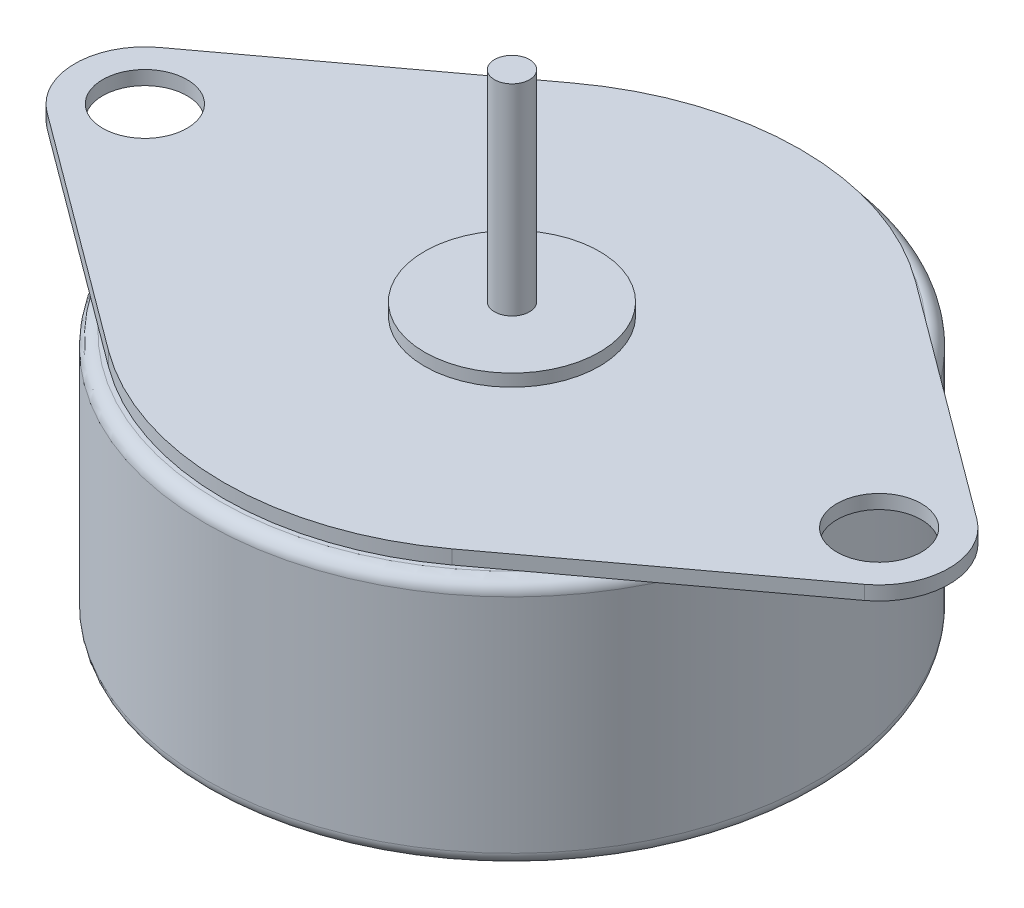
from build123d import *

# Parameters (mm, degrees)
SKETCH1_R      = 17.5
EXTRUDE1_DEPTH = 14.2
FILLET1_R      = 0.75
SKETCH2_R      = 2.413
EXTRUDE2_DEPTH = 0.8
SKETCH3_R      = 5
EXTRUDE3_DEPTH = 2
SKETCH4_R      = 5
EXTRUDE4_DEPTH = 0.7
SKETCH5_R      = 1
EXTRUDE5_DEPTH = 11.5


with BuildPart() as part:
    # Sketch1 → Extrude1 (new body)
    with BuildSketch(Plane(origin=(0, 0, 0), x_dir=(1, 0, 0), z_dir=(0, 1, 0))):
        with Locations(Location((0, 0, 0), (0, 0, 270))):  # turned: the seam where the file's is
            Circle(SKETCH1_R)
    extrude(amount=EXTRUDE1_DEPTH)

    # Fillet1
    fillet1_edges = [part.edges().sort_by_distance(p)[0] for p in [
        (0, 0, -17.5),
        (0, 14.2, -17.5),
    ]]
    fillet(fillet1_edges, radius=FILLET1_R)

    # Sketch2 → Extrude2 (add)
    with BuildSketch(Plane(origin=(0, 14.2, 0), x_dir=(-1, 0, 0), z_dir=(0, 1, 0))):
        with BuildLine():
            Line((23.380952381, -3.21419753), (9.821428571, -13.25856481))
            ThreePointArc((9.821428571, -13.25856481), (0, -16.5), (-9.821428571, -13.25856481))
            Line((-9.821428571, -13.25856481), (-23.380952381, -3.21419753))
            ThreePointArc((-23.380952381, -3.21419753), (-25, 0), (-23.380952381, 3.21419753))
            Line((-23.380952381, 3.21419753), (-9.821428571, 13.25856481))
            ThreePointArc((-9.821428571, 13.25856481), (0, 16.5), (9.821428571, 13.25856481))
            Line((9.821428571, 13.25856481), (23.380952381, 3.21419753))
            ThreePointArc((23.380952381, 3.21419753), (25, 0), (23.380952381, -3.21419753))
        make_face()
        with Locations(Location((21, 0, 0), (0, 0, 90))):  # turned: the seam where the file's is
            Circle(SKETCH2_R, mode=Mode.SUBTRACT)
        with Locations(Location((-21, 0, 0), (0, 0, 270))):  # turned: the seam where the file's is
            Circle(SKETCH2_R, mode=Mode.SUBTRACT)
    extrude(amount=EXTRUDE2_DEPTH)

    # Sketch3 → Extrude3 (add)
    with BuildSketch(Plane.XZ):
        with Locations(Location((0, 0, 0), (0, 0, 90))):  # turned: the seam where the file's is
            Circle(SKETCH3_R)
    extrude(amount=EXTRUDE3_DEPTH)

    # Sketch4 → Extrude4 (add)
    with BuildSketch(Plane(origin=(0, 15, 0), x_dir=(-1, 0, 0), z_dir=(0, 1, 0))):
        with Locations(Location((0, 0, 0), (0, 0, 90))):  # turned: the seam where the file's is
            Circle(SKETCH4_R)
    extrude(amount=EXTRUDE4_DEPTH)

    # Sketch5 → Extrude5 (add)
    with BuildSketch(Plane(origin=(0, 15.7, 0), x_dir=(-1, 0, 0), z_dir=(0, 1, 0))):
        with Locations(Location((0, 0, 0), (0, 0, 90))):  # turned: the seam where the file's is
            Circle(SKETCH5_R)
    extrude(amount=EXTRUDE5_DEPTH)


solid = part.part
